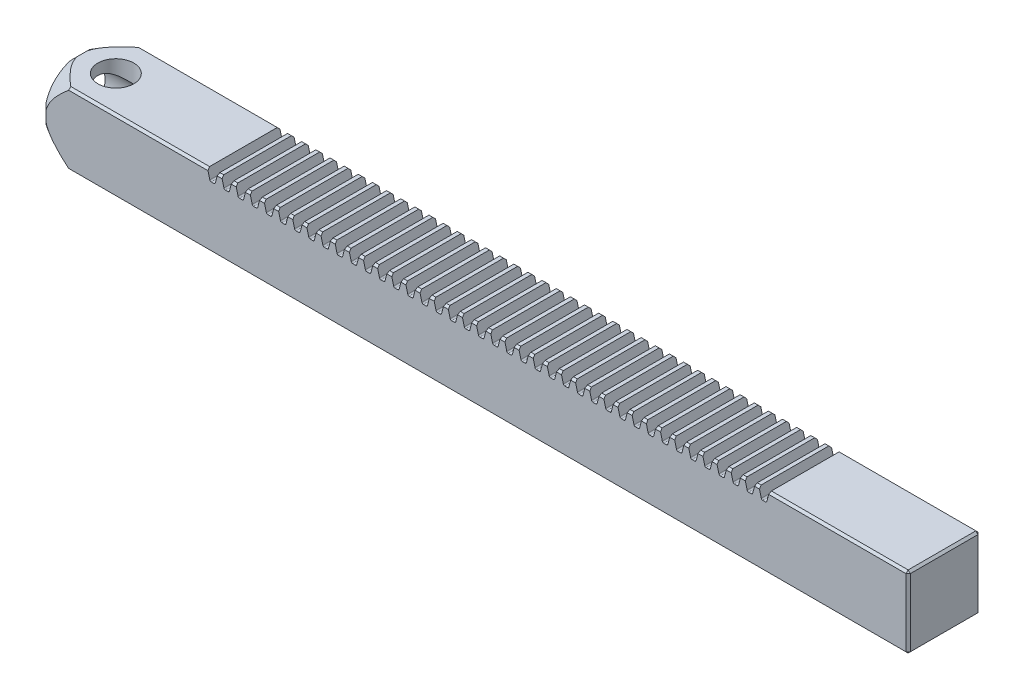
from build123d import *

# Parameters (mm, degrees)
SKETCH1_W           = 1
SKETCH1_H           = 1
BOSS_EXTRUDE1_DEPTH = 12
CHAMFER1_SIZE       = 0.03
CUT_EXTRUDE4_DEPTH  = 1
LPATTERN1_COUNT     = 40
LPATTERN1_PITCH     = 0.19635
SKETCH4_R           = 0.35
CUT_EXTRUDE5_DEPTH  = 1
CUT_EXTRUDE6_REACH  = 3
SKETCH5_R           = 0.25


with BuildPart() as part:
    # Sketch1 → Boss-Extrude1 (new body)
    with BuildSketch(Plane(origin=(0, 0, 0), x_dir=(0, 0, -1), z_dir=(1, 0, 0))):
        Rectangle(SKETCH1_W, SKETCH1_H)
    extrude(amount=BOSS_EXTRUDE1_DEPTH)

    # Chamfer1
    chamfer1_edges = [part.edges().sort_by_distance(p)[0] for p in [
        (12, 0, -0.5),
        (12, 0.5, 0),
        (12, 0, 0.5),
        (0, 0.5, 0),
        (0, 0, -0.5),
        (0, -0.5, 0),
        (0, 0, 0.5),
        (6, 0.5, 0.5),
        (6, 0.5, -0.5),
        (6, -0.5, -0.5),
        (6, -0.5, 0.5),
        (12, -0.5, 0),
    ]]
    chamfer(chamfer1_edges, length=CHAMFER1_SIZE)

    # Sketch2 → Cut-Extrude4 (cut)
    with BuildSketch(Plane.XY.offset(0.5)):
        with BuildLine():
            Line((10.071550762, 0.5), (10.038449238, 0.3720059))
            ThreePointArc((10.038449238, 0.3720059), (10.03133063, 0.361199709), (10.019086285, 0.3570135))
            Line((10.019086285, 0.3570135), (9.980913715, 0.3570135))
            ThreePointArc((9.980913715, 0.3570135), (9.96866937, 0.361199709), (9.961550762, 0.3720059))
            Line((9.961550762, 0.3720059), (9.928449238, 0.5))
            Line((9.928449238, 0.5), (10.071550762, 0.5))
        make_face()
    cut_extrude4 = extrude(amount=-CUT_EXTRUDE4_DEPTH, mode=Mode.SUBTRACT)

    # LPattern1: Cut-Extrude4 ×40
    with Locations(*[(-i * LPATTERN1_PITCH, 0, 0) for i in range(1, LPATTERN1_COUNT)]):
        add(cut_extrude4, mode=Mode.SUBTRACT)

    # Sketch4 → Cut-Extrude5 (cut)
    with BuildSketch(Plane.ZY):
        Circle(SKETCH4_R)
    extrude(amount=-CUT_EXTRUDE5_DEPTH, mode=Mode.SUBTRACT)

    # Sketch5 → Cut-Extrude6 (cut, up to next)
    with BuildSketch(Plane(origin=(0, 0.5, 0), x_dir=(1, 0, 0), z_dir=(0, 1, 0)), mode=Mode.PRIVATE) as cut_extrude6_sk1:
        with Locations((0.5, 0)):
            Circle(SKETCH5_R)
    cut_extrude6_tool1 = extrude(cut_extrude6_sk1.sketch, amount=-CUT_EXTRUDE6_REACH, mode=Mode.PRIVATE) & part.part
    add(cut_extrude6_tool1.solids().sort_by_distance((0.5, 0.5, 0))[0], mode=Mode.SUBTRACT)

    # Sketch6 → Cut-Revolve1 (revolve, cut)
    with BuildSketch(Plane.XY):
        Polygon((0, 0.487438494), (0, 0.687438494), (0.346410162, 0.687438494), align=None)
    revolve(axis=Axis((0, 0, 0), (1, 0, 0)), mode=Mode.SUBTRACT)


solid = part.part
